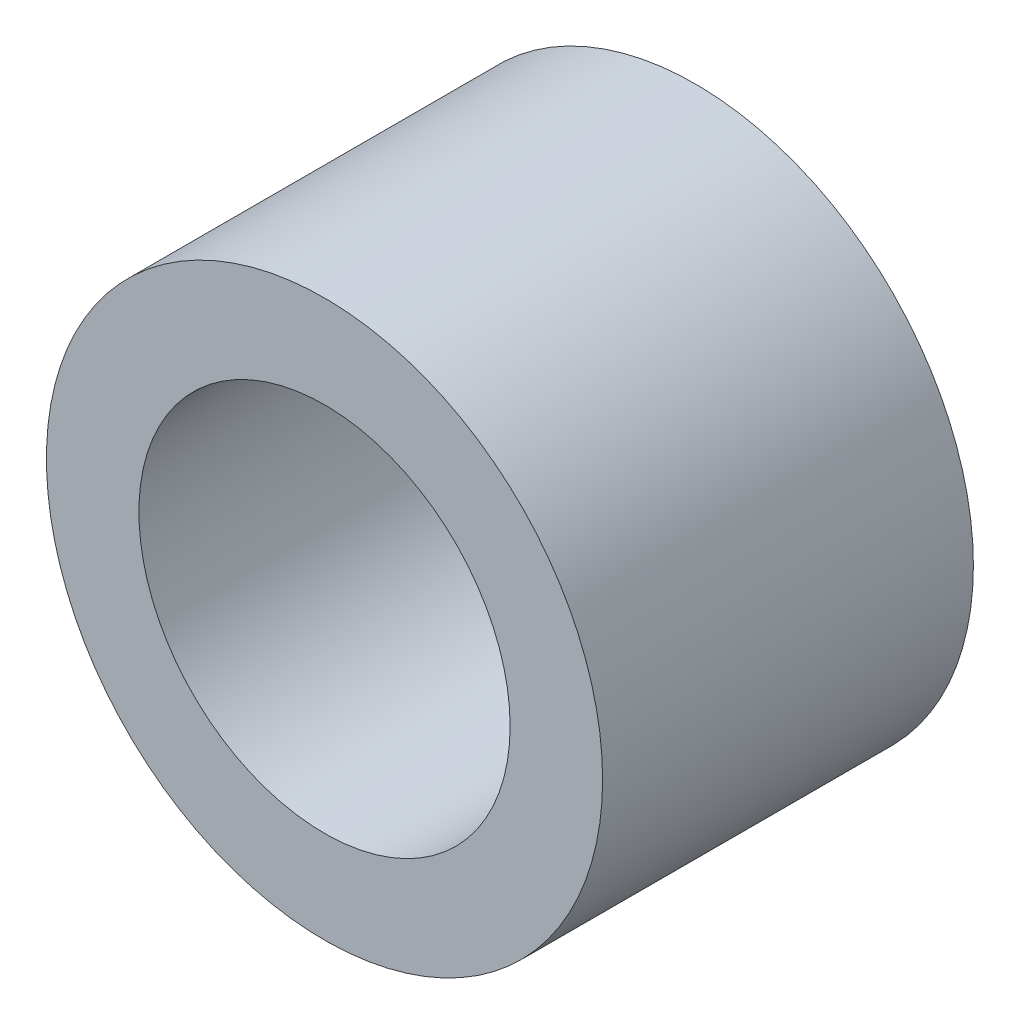
from build123d import *

# Parameters (mm, degrees)
SKETCH3_R                = 4.7625
SKETCH3_R_2              = 3.17881
BOSS_EXTRUDE1_DEPTH      = 3.175
BOSS_EXTRUDE1_DEPTH_BACK = 3.175


with BuildPart() as part:
    # Sketch3 → Boss-Extrude1 (new body, two sides)
    with BuildSketch(Plane.XY) as boss_extrude1_sk:
        Circle(SKETCH3_R)
        Circle(SKETCH3_R_2, mode=Mode.SUBTRACT)
    extrude(amount=BOSS_EXTRUDE1_DEPTH)
    extrude(boss_extrude1_sk.sketch, amount=-BOSS_EXTRUDE1_DEPTH_BACK)


solid = part.part
